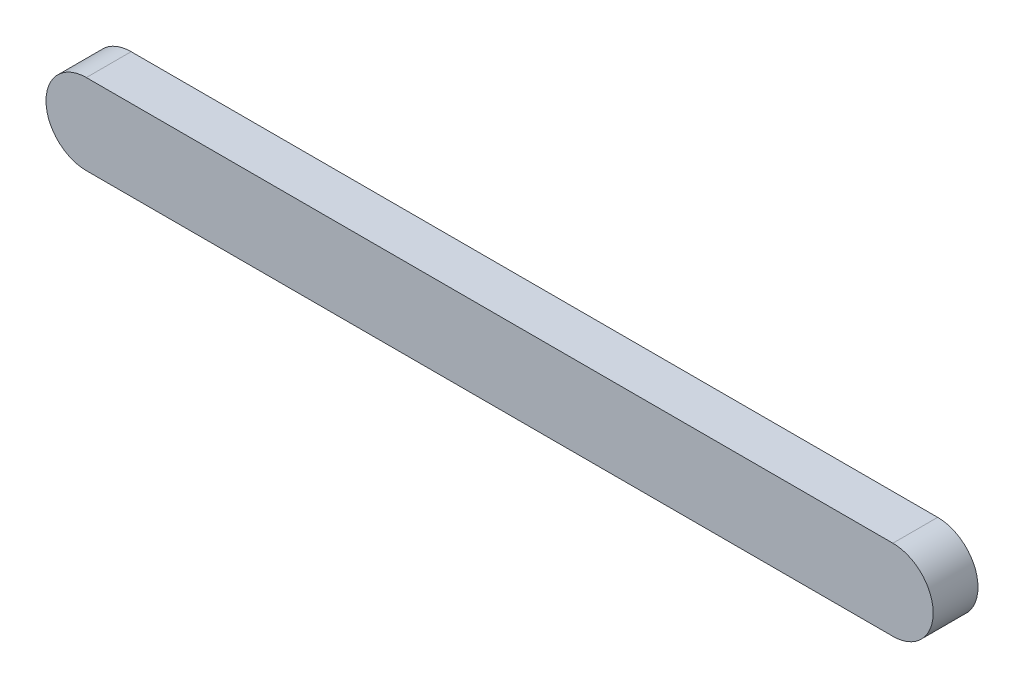
from build123d import *

# Parameters (mm, degrees)
SKETCH1_R           = 4.5
BOSS_EXTRUDE1_DEPTH = 5


with BuildPart() as part:
    # Sketch1 → Boss-Extrude1 (new body)
    with BuildSketch(Plane.XY):
        with BuildLine():
            Line((90, 4.5), (0, 4.5))
            ThreePointArc((0, 4.5), (3.181980515, 3.181980515), (4.5, 0))
            ThreePointArc((4.5, 0), (3.181980515, -3.181980515), (0, -4.5))
            Line((0, -4.5), (90, -4.5))
            ThreePointArc((90, -4.5), (85.5, 0), (90, 4.5))
        make_face()
        with Locations((90, 0)):
            Circle(SKETCH1_R)
        Circle(SKETCH1_R)
    extrude(amount=BOSS_EXTRUDE1_DEPTH)


solid = part.part
